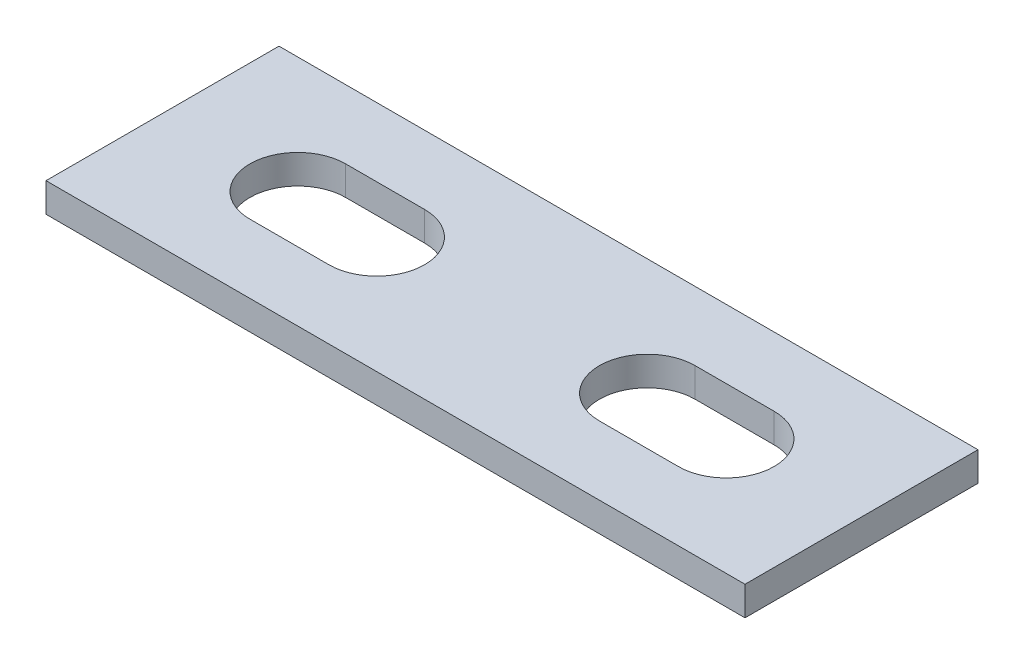
from build123d import *

# Parameters (mm, degrees)
SKETCH1_W           = 76.2
SKETCH1_H           = 25.4
BOSS_EXTRUDE1_DEPTH = 3.175


with BuildPart() as part:
    # Sketch1 → Boss-Extrude1 (new body)
    with BuildSketch(Plane(origin=(0, 0, 0), x_dir=(1, 0, 0), z_dir=(0, 1, 0))):
        Rectangle(SKETCH1_W, SKETCH1_H)
        with BuildLine():
            Line((-23.3553, 5.2197), (-14.7447, 5.2197))
            ThreePointArc((-14.7447, 5.2197), (-9.525, 0), (-14.7447, -5.2197))
            Line((-14.7447, -5.2197), (-23.3553, -5.2197))
            ThreePointArc((-23.3553, -5.2197), (-28.575, 0), (-23.3553, 5.2197))
        make_face(mode=Mode.SUBTRACT)
        with BuildLine():
            Line((23.3553, 5.2197), (14.7447, 5.2197))
            ThreePointArc((14.7447, 5.2197), (9.525, 0), (14.7447, -5.2197))
            Line((14.7447, -5.2197), (23.3553, -5.2197))
            ThreePointArc((23.3553, -5.2197), (28.575, 0), (23.3553, 5.2197))
        make_face(mode=Mode.SUBTRACT)
    extrude(amount=BOSS_EXTRUDE1_DEPTH)


solid = part.part
